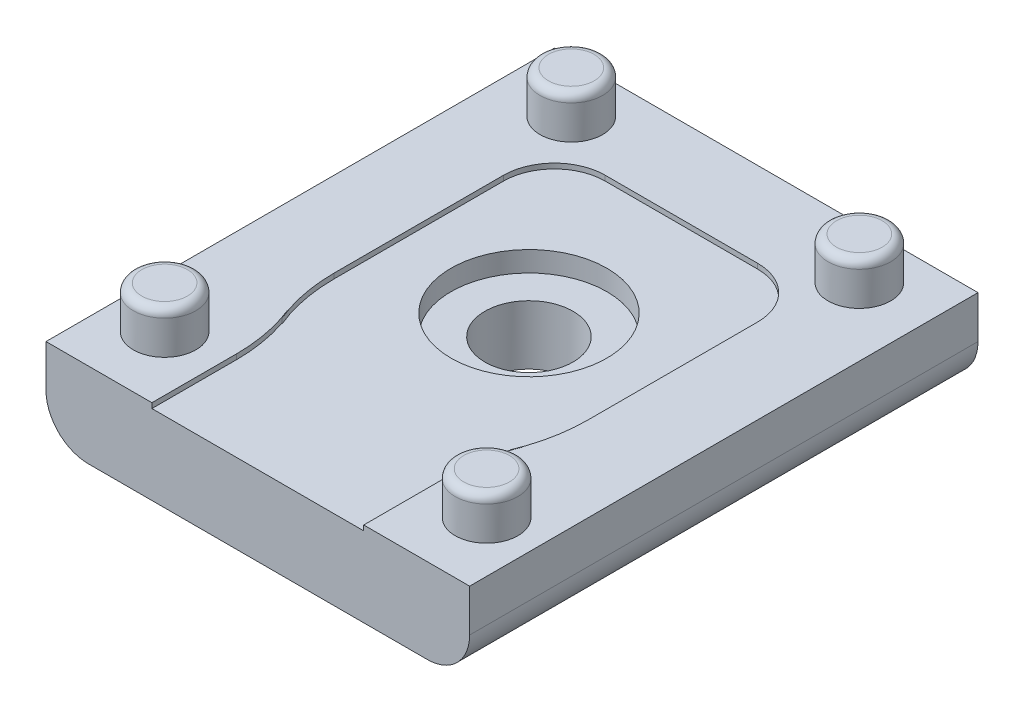
from build123d import *

# Parameters (mm, degrees)
SKETCH1_W           = 25
SKETCH1_H           = 30
BOSS_EXTRUDE1_DEPTH = 5
CUT_EXTRUDE1_DEPTH  = 0.3
SKETCH3_R           = 1.85
BOSS_EXTRUDE2_DEPTH = 2.5
FILLET3_R           = 2.5
SKETCH2_3_R         = 2.6
CUT_EXTRUDE7_DEPTH  = 10
SKETCH2_4_R         = 4.6
CUT_EXTRUDE8_DEPTH  = 1.5
FILLET4_R           = 0.5


with BuildPart() as part:
    # Sketch1 → Boss-Extrude1 (new body)
    with BuildSketch(Plane(origin=(0, 0, 0), x_dir=(1, 0, 0), z_dir=(0, 1, 0))):
        with Locations((12.5, 15)):
            Rectangle(SKETCH1_W, SKETCH1_H)
    extrude(amount=BOSS_EXTRUDE1_DEPTH)

    # Sketch2 → Cut-Extrude1 (cut)
    with BuildSketch(Plane(origin=(0, 5, 0), x_dir=(1, 0, 0), z_dir=(0, 1, 0))):
        with BuildLine():
            Line((8, 25), (17, 25))
            ThreePointArc((17, 25), (19.121320344, 24.121320344), (20, 22))
            Line((20, 22), (20, 12))
            ThreePointArc((20, 12), (19.805806757, 10.038838649), (19.230769231, 8.153846154))
            Line((19.230769231, 8.153846154), (19.519230769, 8.846153846))
            ThreePointArc((19.519230769, 8.846153846), (18.944193243, 6.961161351), (18.75, 5))
            Line((18.75, 5), (18.75, 0))
            Line((18.75, 0), (6.25, 0))
            Line((6.25, 0), (6.25, 5))
            ThreePointArc((6.25, 5), (6.055806757, 6.961161351), (5.480769231, 8.846153846))
            Line((5.480769231, 8.846153846), (5.769230769, 8.153846154))
            ThreePointArc((5.769230769, 8.153846154), (5.194193243, 10.038838649), (5, 12))
            Line((5, 12), (5, 22))
            ThreePointArc((5, 22), (5.878679656, 24.121320344), (8, 25))
        make_face()
    extrude(amount=-CUT_EXTRUDE1_DEPTH, mode=Mode.SUBTRACT)

    # Sketch3 → Boss-Extrude2 (add)
    with BuildSketch(Plane(origin=(0, 5, 0), x_dir=(1, 0, 0), z_dir=(0, 1, 0))):
        with Locations((21, 27)):
            Circle(SKETCH3_R)
        with Locations((4, 27)):
            Circle(SKETCH3_R)
        with Locations((3, 4)):
            Circle(SKETCH3_R)
        with Locations((22, 4)):
            Circle(SKETCH3_R)
    extrude(amount=BOSS_EXTRUDE2_DEPTH)

    # Fillet3
    fillet3_edges = [part.edges().sort_by_distance(p)[0] for p in [
        (25, 0, -15),
        (0, 0, -15),
    ]]
    fillet(fillet3_edges, radius=FILLET3_R)

    # Sketch2_3 → Cut-Extrude7 (cut)
    with BuildSketch(Plane(origin=(0, 5, 0), x_dir=(1, 0, 0), z_dir=(0, 1, 0))):
        with Locations((12.5, 16)):
            Circle(SKETCH2_3_R)
    extrude(amount=-CUT_EXTRUDE7_DEPTH, mode=Mode.SUBTRACT)

    # Sketch2_4 → Cut-Extrude8 (cut)
    with BuildSketch(Plane(origin=(0, 5, 0), x_dir=(1, 0, 0), z_dir=(0, 1, 0))):
        with Locations((12.5, 16)):
            Circle(SKETCH2_4_R)
    extrude(amount=-CUT_EXTRUDE8_DEPTH, mode=Mode.SUBTRACT)

    # Fillet4
    fillet4_edges = [part.edges().sort_by_distance(p)[0] for p in [
        (20.15, 7.5, -4),
        (1.15, 7.5, -4),
        (2.15, 7.5, -27),
        (19.15, 7.5, -27),
    ]]
    fillet(fillet4_edges, radius=FILLET4_R)


solid = part.part
